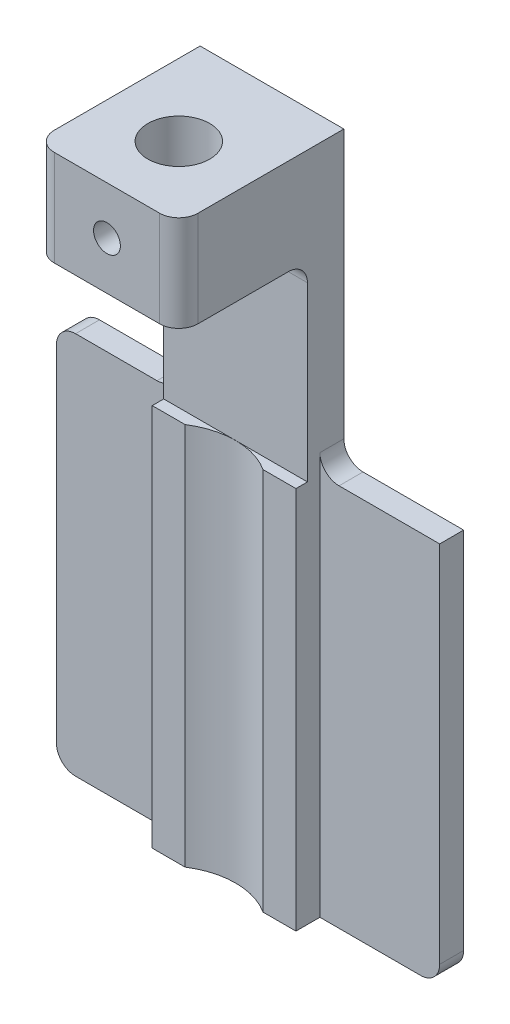
from build123d import *

# Parameters (mm, degrees)
BOSS_EXTRUDE1_DEPTH        = 4.7625
SKETCH3_R                  = 2.05
CUT_EXTRUDE1_DEPTH         = 46.128865832
SKETCH4_R                  = 4.7625
CUT_EXTRUDE2_DEPTH         = 38.1
SKETCH5_W                  = 25.4
SKETCH5_H                  = 25.4
BOSS_EXTRUDE2_DEPTH        = 1.5875
SKETCH6_W                  = 23.891441553
SKETCH6_H                  = 12.7
CUT_EXTRUDE3_DEPTH         = 0.762
FILLET1_R                  = 1.27
F_2_56_TAPPED_HOLE1_REACH  = 32.432
F_2_56_TAPPED_HOLE1_BORE_R = 0.889


with BuildPart() as part:
    # Sketch2 → Boss-Extrude1 (new, symmetric)
    with BuildSketch(Plane(origin=(0, 0, 0), x_dir=(0, 0, -1), z_dir=(1, 0, 0))):
        Polygon((-4.7625, 12.7), (3, 12.7), (3, -25.4), (6.175, -25.4), (6.175, 19.05), (-4.7625, 19.05), align=None)
    extrude(amount=BOSS_EXTRUDE1_DEPTH, both=True)

    # Sketch3 → Cut-Extrude1 (cut, through all)
    with BuildSketch(Plane(origin=(0, 19.05, 0), x_dir=(1, 0, 0), z_dir=(0, 1, 0))):
        with Locations(Location((0, 0, 0), (0, 0, 270))):
            Circle(SKETCH3_R)
    extrude(amount=-CUT_EXTRUDE1_DEPTH, mode=Mode.SUBTRACT)

    # Sketch4 → Cut-Extrude2 (cut)
    with BuildSketch(Plane.XZ.offset(25.4)):
        with Locations((0, 1.0005)):
            Circle(SKETCH4_R)
    extrude(amount=-CUT_EXTRUDE2_DEPTH, mode=Mode.SUBTRACT)

    # Sketch5 → Boss-Extrude2 (add)
    with BuildSketch(Plane(origin=(0, 0, -6.175), x_dir=(-1, 0, 0), z_dir=(0, 0, -1))):
        with Locations((0, -12.7)):
            Rectangle(SKETCH5_W, SKETCH5_H)
    extrude(amount=-BOSS_EXTRUDE2_DEPTH)

    # Sketch6 → Cut-Extrude3 (cut)
    with BuildSketch(Plane.XY.offset(-3)):
        with Locations((3.216659965, 6.35)):
            Rectangle(SKETCH6_W, SKETCH6_H)
    extrude(amount=-CUT_EXTRUDE3_DEPTH, mode=Mode.SUBTRACT)

    # Fillet1
    fillet1_edges = [part.edges().sort_by_distance(p)[0] for p in [
        (4.7625, 15.875, 4.7625),
        (-4.7625, 0, -5.38125),
        (-12.7, -25.4, -5.38125),
        (-12.7, 0, -5.38125),
        (12.7, -25.4, -5.38125),
        (4.7625, 0, -5.38125),
        (0, 12.7, -3.762),
        (-4.7625, 15.875, 4.7625),
    ]]
    fillet(fillet1_edges, radius=FILLET1_R)

    # #2-56 Tapped Hole1 bore → #2-56 Tapped Hole1 (cut, up to next)
    with BuildSketch(Plane.XY.offset(4.7625), mode=Mode.PRIVATE) as f_2_56_tapped_hole1_sk1:
        with Locations((0, 15.875)):
            Circle(F_2_56_TAPPED_HOLE1_BORE_R)
    f_2_56_tapped_hole1_tool1 = extrude(f_2_56_tapped_hole1_sk1.sketch, amount=-F_2_56_TAPPED_HOLE1_REACH, mode=Mode.PRIVATE) & part.part
    add(f_2_56_tapped_hole1_tool1.solids().sort_by_distance((0, 15.875, 4.7625))[0], mode=Mode.SUBTRACT)


solid = part.part
